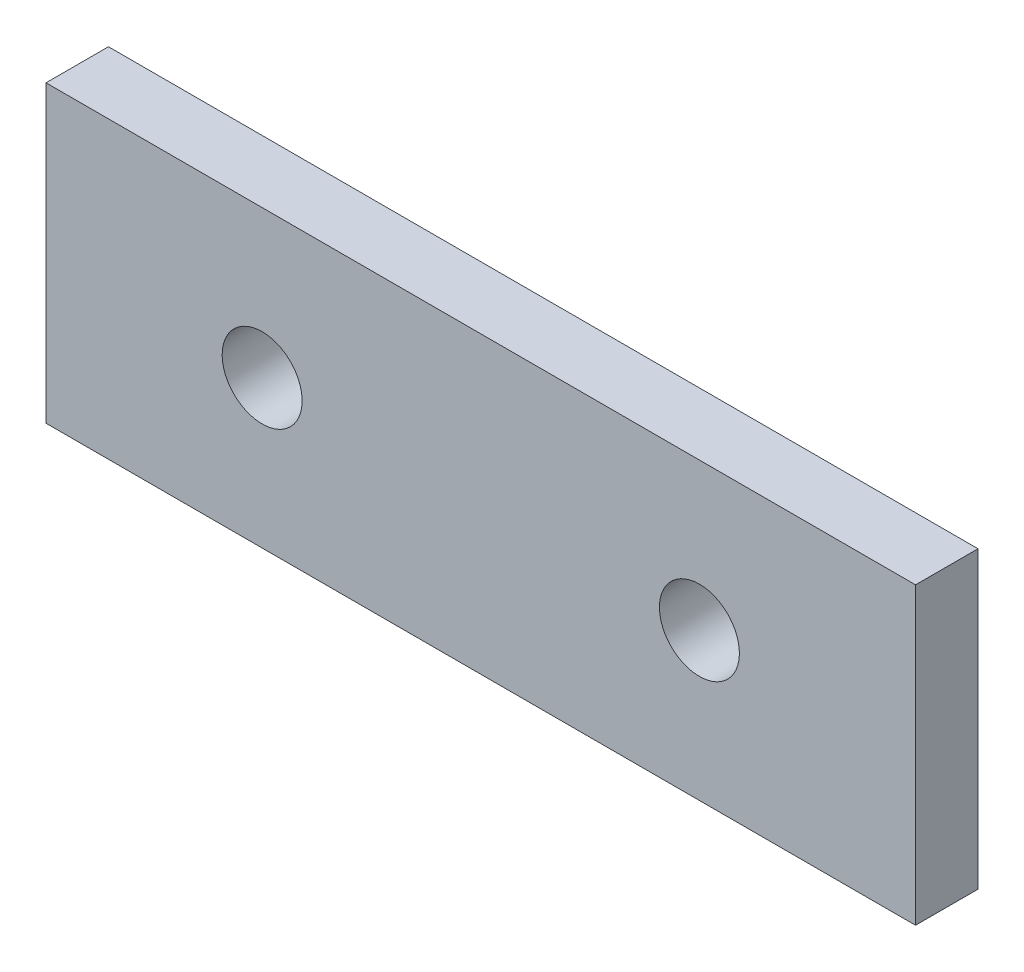
from build123d import *

# Parameters (mm, degrees)
CROQUIS1_W              = 34.8
CROQUIS1_H              = 11.8
CROQUIS1_R              = 1.6
SALIENTE_EXTRUIR1_DEPTH = 2.5


with BuildPart() as part:
    # Croquis1 → Saliente-Extruir1 (new body)
    with BuildSketch(Plane.XY):
        with Locations((0, -24)):
            Rectangle(CROQUIS1_W, CROQUIS1_H)
        with Locations((8.75, -24)):
            Circle(CROQUIS1_R, mode=Mode.SUBTRACT)
        with Locations((-8.75, -24)):
            Circle(CROQUIS1_R, mode=Mode.SUBTRACT)
    extrude(amount=SALIENTE_EXTRUIR1_DEPTH)


solid = part.part
